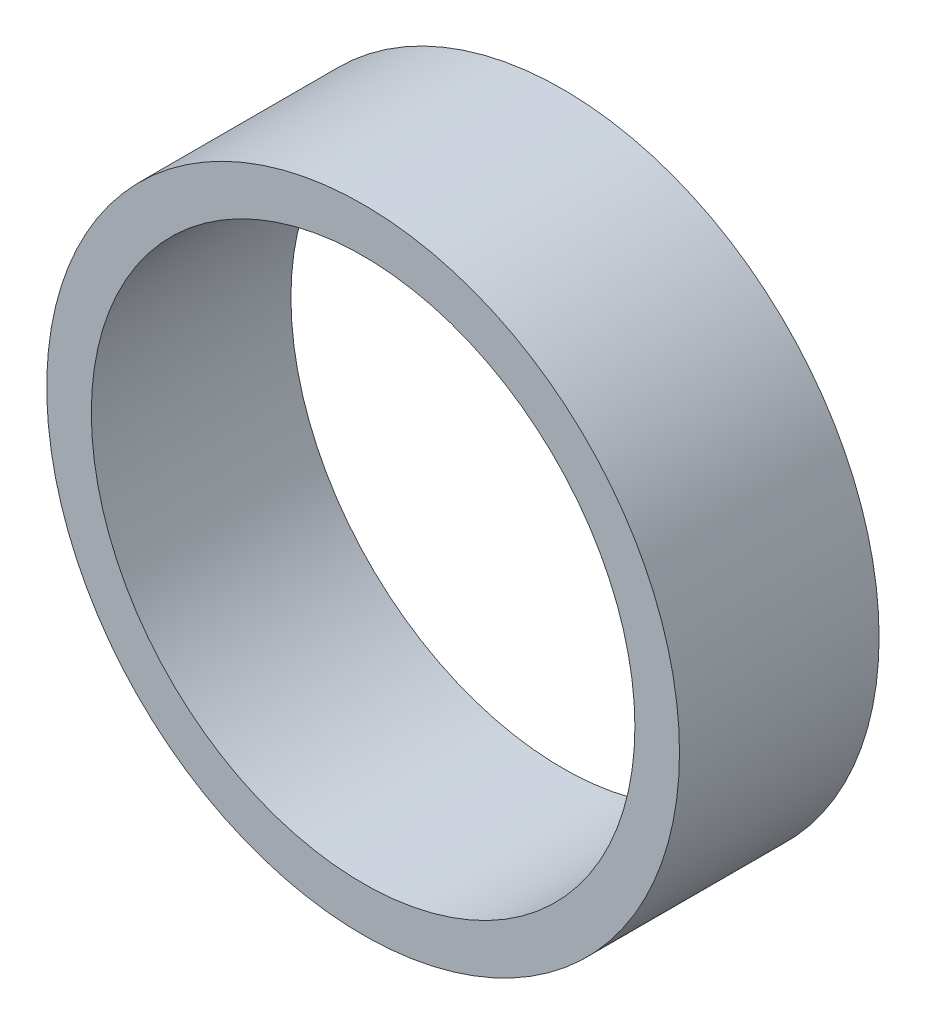
from build123d import *

# Parameters (mm, degrees)
SKETCH1_R           = 7.45
SKETCH1_R_2         = 6.4
BOSS_EXTRUDE1_DEPTH = 4.7


with BuildPart() as part:
    # Sketch1 → Boss-Extrude1 (new body)
    with BuildSketch(Plane.XY):
        Circle(SKETCH1_R)
        Circle(SKETCH1_R_2, mode=Mode.SUBTRACT)
    extrude(amount=BOSS_EXTRUDE1_DEPTH)


solid = part.part
